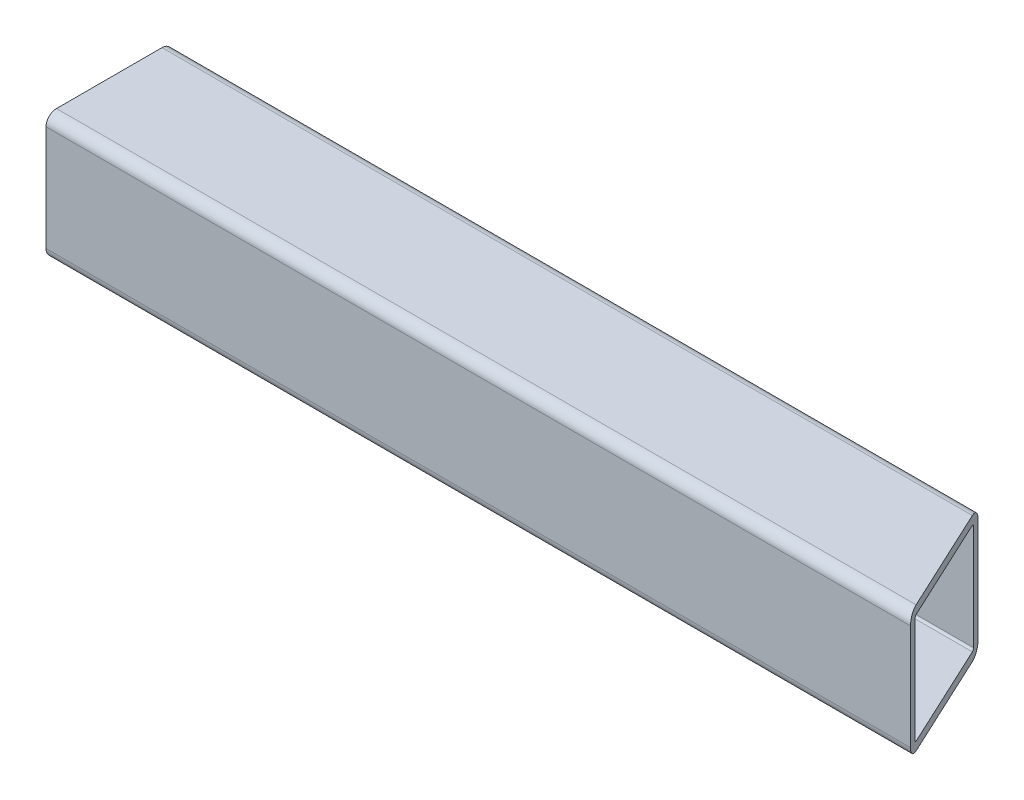
from build123d import *

# Parameters (mm, degrees)
EXTRUDE_THIN1_DEPTH     = 130.175
CUT_EXTRUDE1_DEPTH      = 1
CUT_EXTRUDE1_DEPTH_BACK = 39.1


with BuildPart() as part:
    # Sketch1 → Extrude-Thin1 (new body, symmetric)
    with BuildSketch(Plane(origin=(0, 0, 0), x_dir=(0, 0, -1), z_dir=(1, 0, 0))):
        with BuildLine():
            Line((-15.875, 19.05), (15.875, 19.05))
            ThreePointArc((15.875, 19.05), (18.12006403, 18.12006403), (19.05, 15.875))
            Line((19.05, 15.875), (19.05, -15.875))
            ThreePointArc((19.05, -15.875), (18.12006403, -18.12006403), (15.875, -19.05))
            Line((15.875, -19.05), (-15.875, -19.05))
            ThreePointArc((-15.875, -19.05), (-18.12006403, -18.12006403), (-19.05, -15.875))
            Line((-19.05, -15.875), (-19.05, 15.875))
            ThreePointArc((-19.05, 15.875), (-18.12006403, 18.12006403), (-15.875, 19.05))
        make_face()
        with BuildLine():
            Line((-15.875, 16.51), (15.875, 16.51))
            ThreePointArc((15.875, 16.51), (16.324012806, 16.324012806), (16.51, 15.875))
            Line((16.51, 15.875), (16.51, -15.875))
            ThreePointArc((16.51, -15.875), (16.324012806, -16.324012806), (15.875, -16.51))
            Line((15.875, -16.51), (-15.875, -16.51))
            ThreePointArc((-15.875, -16.51), (-16.324012806, -16.324012806), (-16.51, -15.875))
            Line((-16.51, -15.875), (-16.51, 15.875))
            ThreePointArc((-16.51, 15.875), (-16.324012806, 16.324012806), (-15.875, 16.51))
        make_face(mode=Mode.SUBTRACT)
    extrude(amount=EXTRUDE_THIN1_DEPTH, both=True)

    # Sketch3 → Cut-Extrude1 (cut, two sides)
    with BuildSketch(Plane(origin=(0, 19.05, 0), x_dir=(1, 0, 0), z_dir=(0, 1, 0))) as cut_extrude1_sk:
        Polygon((356.802383498, -505.053992289), (130.175, -19.05), (112.408678224, 19.05), (-114.218705274, 505.053992289), (857.789279304, 958.308759286), (1328.810368077, -51.799225292), align=None)
    extrude(amount=CUT_EXTRUDE1_DEPTH, mode=Mode.SUBTRACT)
    extrude(cut_extrude1_sk.sketch, amount=-CUT_EXTRUDE1_DEPTH_BACK, mode=Mode.SUBTRACT)


solid = part.part
